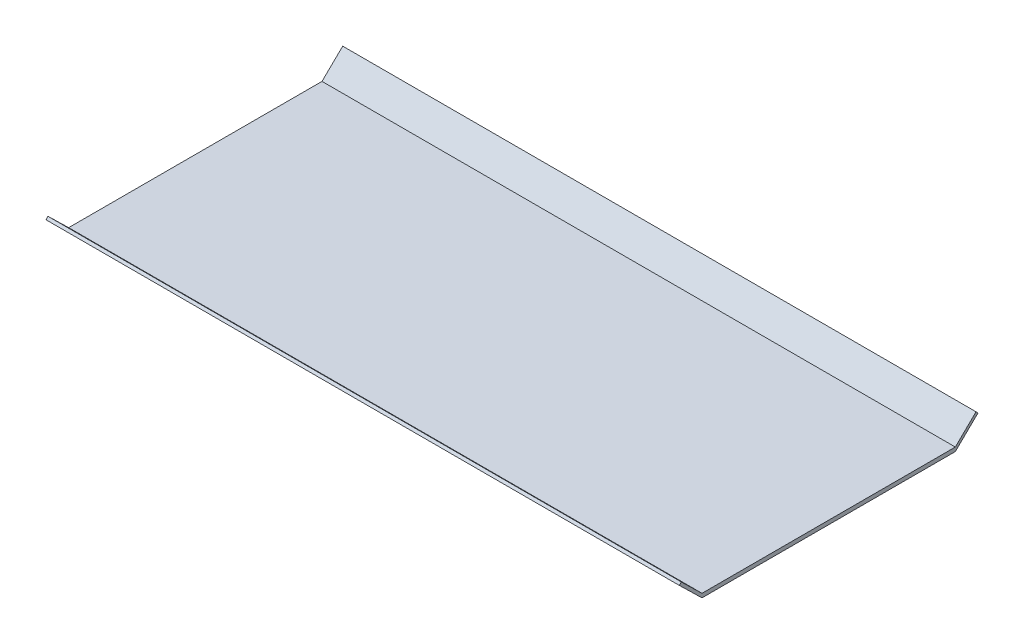
from build123d import *

# Parameters (mm, degrees)
SKETCH1_W           = 1016
SKETCH1_H           = 406.4
BOSS_EXTRUDE1_DEPTH = 6.35
BOSS_EXTRUDE2_DEPTH = 1016


with BuildPart() as part:
    # Sketch1 → Boss-Extrude1 (new body)
    with BuildSketch(Plane(origin=(0, 0, 0), x_dir=(1, 0, 0), z_dir=(0, 1, 0))):
        with Locations((508, 203.2)):
            Rectangle(SKETCH1_W, SKETCH1_H)
    extrude(amount=BOSS_EXTRUDE1_DEPTH)

    # Sketch2 → Boss-Extrude2 (add)
    with BuildSketch(Plane(origin=(0, 0, 0), x_dir=(0, 0, -1), z_dir=(1, 0, 0))):
        Polygon((0, 0), (-36.378303543, 35.457848656), (-33.204345912, 38.714199465), (0, 6.35), align=None)
        Polygon((406.4, 6.35), (406.4, 0), (442.778303543, 35.457848656), (439.604345912, 38.714199465), align=None)
    extrude(amount=BOSS_EXTRUDE2_DEPTH)


solid = part.part
